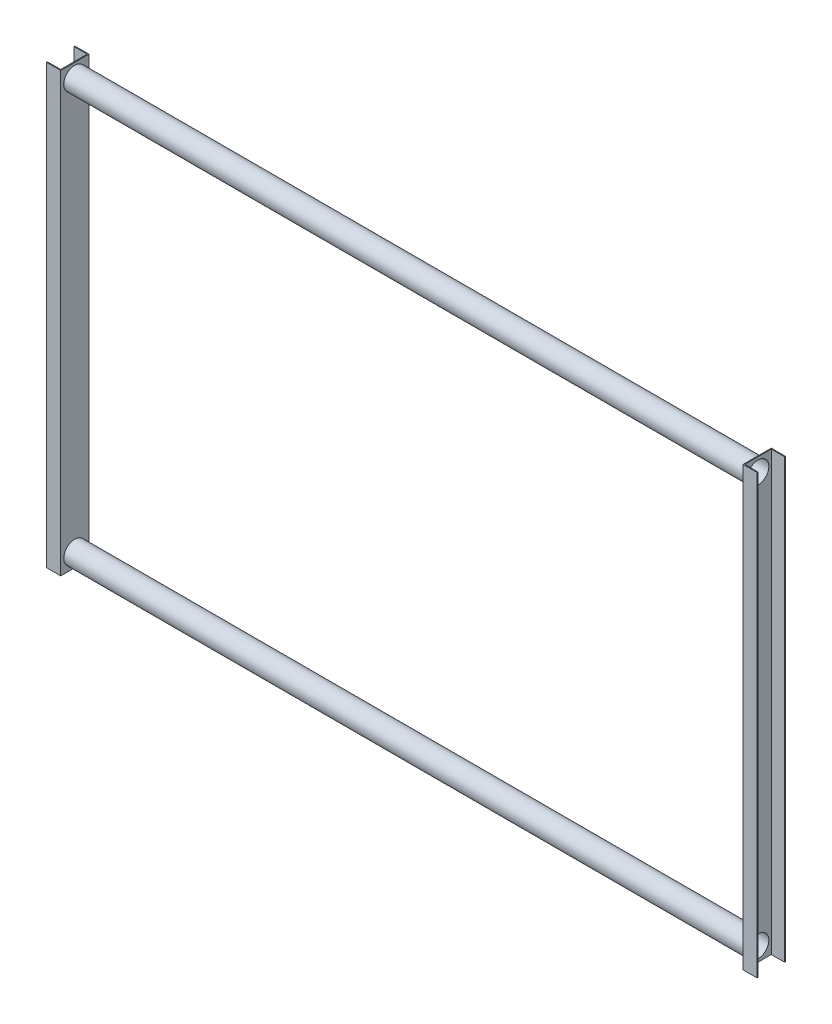
from build123d import *

# Parameters (mm, degrees)
BOSS_EXTRUDE1_DEPTH   = 1600
BOSS_EXTRUDE1_2_DEPTH = 1600
SKETCH7_R             = 39.5
CUT_EXTRUDE2_DEPTH    = 2549.5
SKETCH8_R             = 40.5
SKETCH8_R_2           = 39.5
BOSS_EXTRUDE2_DEPTH   = 2494


with BuildPart() as part:
    # Sketch3 → Boss-Extrude1 (new body)
    with BuildSketch(Plane(origin=(0, 0, 0), x_dir=(1, 0, 0), z_dir=(0, 1, 0))):
        Polygon((-51.5, 51.5), (0, 51.5), (0, -51.5), (-51.5, -51.5), (-51.5, -48.5), (-3, -48.5), (-3, 48.5), (-51.5, 48.5), align=None)
    extrude(amount=BOSS_EXTRUDE1_DEPTH)


with BuildPart() as body_2:
    # Sketch3 → Boss-Extrude1 2 (new body)
    with BuildSketch(Plane(origin=(0, 0, 0), x_dir=(1, 0, 0), z_dir=(0, 1, 0))):
        Polygon((2497, 48.5), (2545.5, 48.5), (2545.5, 51.5), (2494, 51.5), (2494, -51.5), (2545.5, -51.5), (2545.5, -48.5), (2497, -48.5), align=None)
    extrude(amount=BOSS_EXTRUDE1_2_DEPTH)


with BuildPart() as cut_extrude2_tool:
    # Sketch7 → Cut-Extrude2 (new body, through all)
    with BuildSketch(Plane.ZY.offset(3)):
        with Locations((0, 50)):
            Circle(SKETCH7_R)
        with Locations((0, 1550)):
            Circle(SKETCH7_R)
    extrude(amount=-CUT_EXTRUDE2_DEPTH)


with BuildPart() as part_1:
    add(part.part)

    # Cut-Extrude2: cut by cut_extrude2_tool
    add(cut_extrude2_tool.part, mode=Mode.SUBTRACT)



with BuildPart() as body_2_1:
    add(body_2.part)

    # Cut-Extrude2: cut by cut_extrude2_tool
    add(cut_extrude2_tool.part, mode=Mode.SUBTRACT)


with BuildPart() as part_2:
    add(part_1.part)

    add(body_2_1.part)  # Boss-Extrude2 merges body 2
    # Sketch8 → Boss-Extrude2 (add)
    with BuildSketch(Plane(origin=(0, 0, 0), x_dir=(0, 0, -1), z_dir=(1, 0, 0))):
        with Locations((0, 50)):
            Circle(SKETCH8_R)
        with Locations((0, 50)):
            Circle(SKETCH8_R_2, mode=Mode.SUBTRACT)
        with Locations((0, 1550)):
            Circle(SKETCH8_R)
        with Locations((0, 1550)):
            Circle(SKETCH8_R_2, mode=Mode.SUBTRACT)
    extrude(amount=BOSS_EXTRUDE2_DEPTH)


solid = part_2.part
